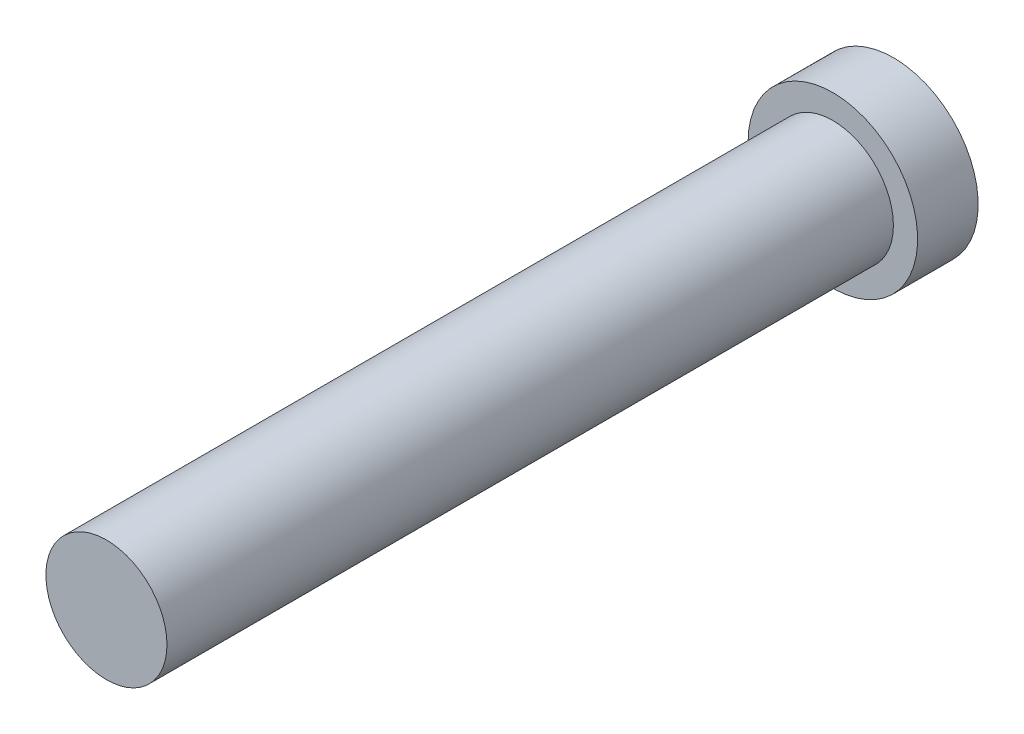
from build123d import *

# Parameters (mm, degrees)
SKETCH1_R           = 2.5
BOSS_EXTRUDE1_DEPTH = 30
SKETCH2_R           = 3.5
BOSS_EXTRUDE2_DEPTH = 2.5


with BuildPart() as part:
    # Sketch1 → Boss-Extrude1 (new body)
    with BuildSketch(Plane.XY):
        Circle(SKETCH1_R)
    extrude(amount=BOSS_EXTRUDE1_DEPTH)

    # Sketch2 → Boss-Extrude2 (add)
    with BuildSketch(Plane(origin=(0, 0, 0), x_dir=(-1, 0, 0), z_dir=(0, 0, -1))):
        Circle(SKETCH2_R)
    extrude(amount=BOSS_EXTRUDE2_DEPTH)


solid = part.part
